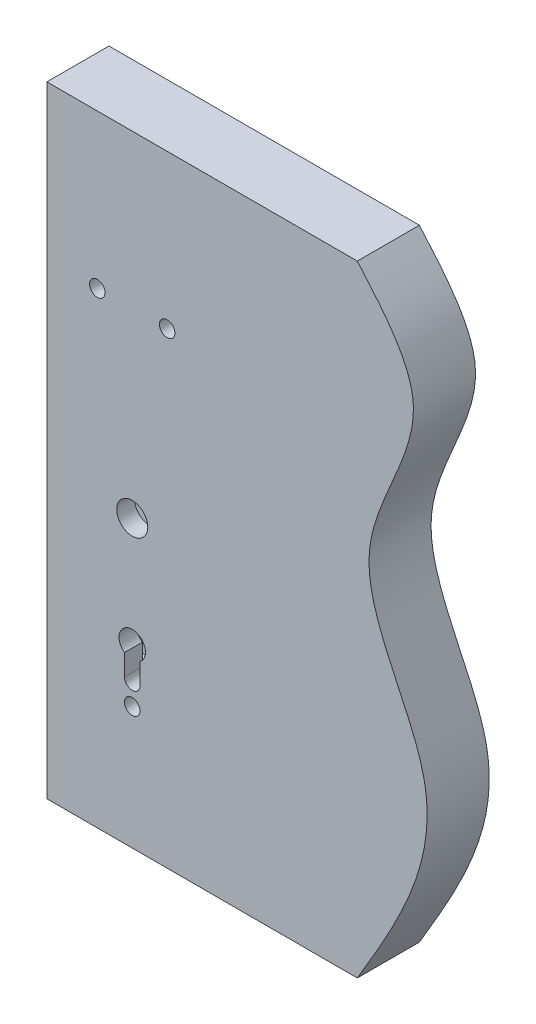
from build123d import *

# Parameters (mm, degrees)
EXTRUSION1_DEPTH        = 20
ESQUISSE2_W             = 22
ESQUISSE2_H             = 230
ENL_V_MAT_EXTRU_1_DEPTH = 3
ESQUISSE3_W             = 163
ESQUISSE3_H             = 77
ENL_V_MAT_EXTRU_2_DEPTH = 8.5
ESQUISSE4_R             = 10
ESQUISSE4_R_2           = 5
ENL_V_MAT_EXTRU_3_DEPTH = 41.0000001
ENL_V_MAT_EXTRU_4_DEPTH = 41.0000001


with BuildPart() as part:
    # Esquisse1 → Extrusion1 (new body, symmetric)
    with BuildSketch(Plane.XY):
        with BuildLine():
            Line((-150, 200), (50, 200))
            add(Edge.make_bspline(
                [(50, 200), (66.879560662, 180.562572919), (108.794009551, 132.296562907), (27.278256401, 35.236557066), (123.473848535, -75.99379889), (75.892612143, -156.299492504), (50, -200)],
                knots=[0, 0, 0, 0, 0.163803914, 0.406749376, 0.677166684, 1, 1, 1, 1], degree=3))
            Line((50, -200), (-150, -200))
            Line((-150, -200), (-150, 200))
        make_face()
    extrude(amount=EXTRUSION1_DEPTH, both=True)

    # Esquisse2 → Enlèv. mat.-Extru.1 (cut)
    with BuildSketch(Plane.ZY.offset(150)):
        with Locations((0, -35)):
            Rectangle(ESQUISSE2_W, ESQUISSE2_H)
    extrude(amount=-ENL_V_MAT_EXTRU_1_DEPTH, mode=Mode.SUBTRACT)

    # Esquisse3 → Enlèv. mat.-Extru.2 (cut, symmetric)
    with BuildSketch(Plane(origin=(37.152504758, -36.321343777, 0), x_dir=(0, 1, 0), z_dir=(0, 0, 1))):
        with Locations((1.321343777, 145.652504758)):
            Rectangle(ESQUISSE3_W, ESQUISSE3_H)
    extrude(amount=ENL_V_MAT_EXTRU_2_DEPTH, both=True, mode=Mode.SUBTRACT)

    # Esquisse4 → Enlèv. mat.-Extru.3 (cut, through all)
    with BuildSketch(Plane.XY.offset(20)):
        with Locations((-95, -16)):
            Circle(ESQUISSE4_R)
        with Locations((-117.5, 101)):
            Circle(ESQUISSE4_R_2)
        with Locations((-95, -121)):
            Circle(ESQUISSE4_R_2)
        with Locations((-72.5, 101)):
            Circle(ESQUISSE4_R_2)
    extrude(amount=-ENL_V_MAT_EXTRU_3_DEPTH, mode=Mode.SUBTRACT)

    # Esquisse5 → Enlèv. mat.-Extru.4 (cut, through all)
    with BuildSketch(Plane(origin=(0, 0, -20), x_dir=(-1, 0, 0), z_dir=(0, 0, -1))):
        with BuildLine():
            Line((90, -93.373863542), (90, -107))
            ThreePointArc((90, -107), (95, -112), (100, -107))
            Line((100, -107), (100, -93.373863542))
            ThreePointArc((100, -93.373863542), (102.717833431, -82.93839262), (93.013889057, -78.235294118))
            ThreePointArc((93.013889057, -78.235294118), (86.663603441, -84.840333643), (90, -93.373863542))
        make_face()
    extrude(amount=-ENL_V_MAT_EXTRU_4_DEPTH, mode=Mode.SUBTRACT)


solid = part.part
